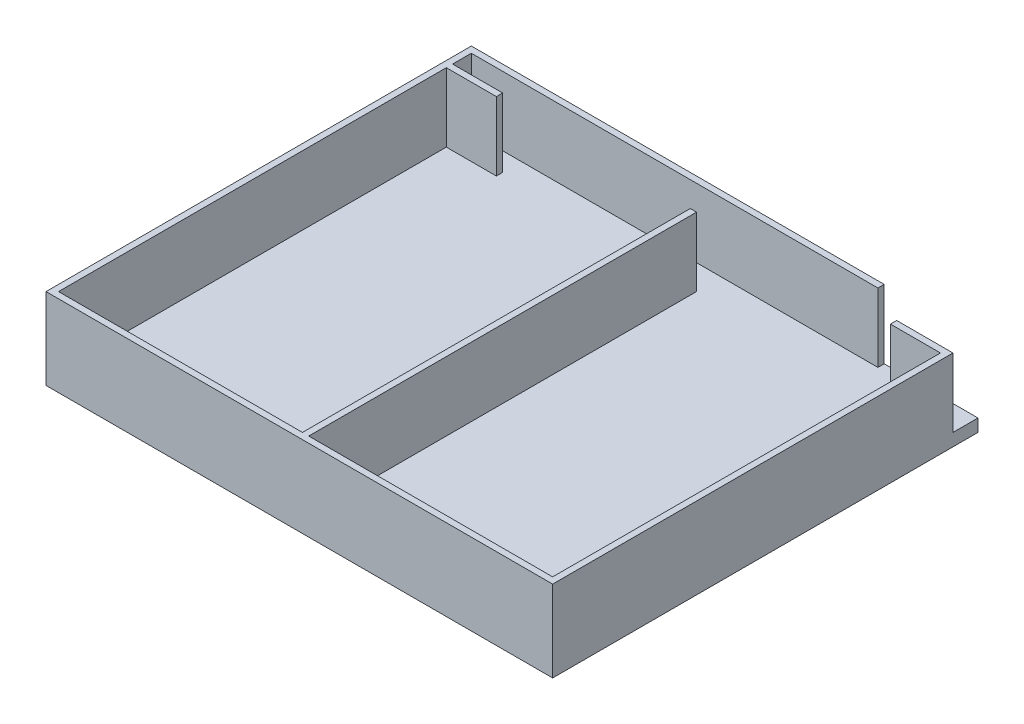
from build123d import *

# Parameters (mm, degrees)
SKETCH1_W           = 81
SKETCH1_H           = 68
BOSS_EXTRUDE1_DEPTH = 2
BOSS_EXTRUDE2_DEPTH = 11


with BuildPart() as part:
    # Sketch1 → Boss-Extrude1 (new body)
    with BuildSketch(Plane(origin=(0, 0, 0), x_dir=(1, 0, 0), z_dir=(0, 1, 0))):
        Rectangle(SKETCH1_W, SKETCH1_H)
    extrude(amount=-BOSS_EXTRUDE1_DEPTH)

    # Sketch1_3 → Boss-Extrude2 (add)
    with BuildSketch(Plane(origin=(0, 0, 0), x_dir=(1, 0, 0), z_dir=(0, 1, 0))):
        Polygon((0.5, 29), (-0.5, 29), (-0.5, -33), (-39.5, -33), (-39.5, 29), (-31.5, 29), (-31.5, 30), (-39.5, 30), (-39.5, 33), (25.5, 33), (25.5, 34), (-40.5, 34), (-40.5, -34), (40.5, -34), (40.5, 30), (31.5, 30), (31.5, 29), (39.5, 29), (39.5, -33), (0.5, -33), align=None)
    extrude(amount=BOSS_EXTRUDE2_DEPTH)


solid = part.part
